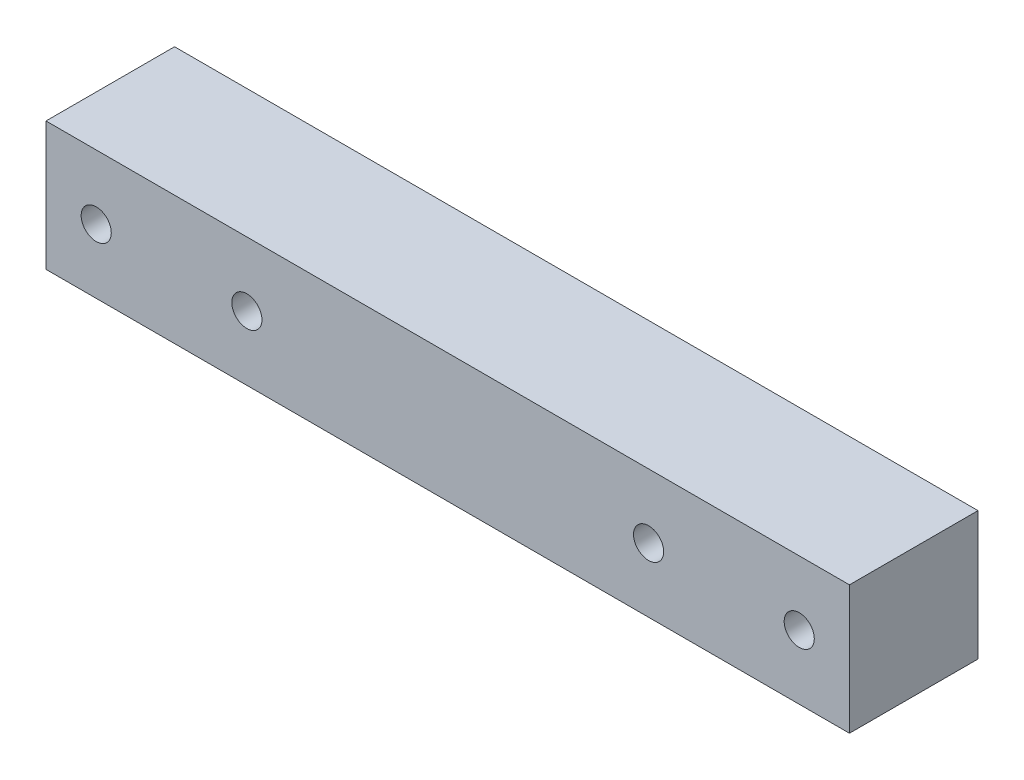
from build123d import *

# Parameters (mm, degrees)
ESBO_O1_W                = 80
ESBO_O1_H                = 12.8
RESSALTO_EXTRUS_O1_DEPTH = 12.8
ESBO_O2_R                = 1.5
CORTE_EXTRUS_O1_DEPTH    = 12.8


with BuildPart() as part:
    # Esboço1 → Ressalto-extrusão1 (new body)
    with BuildSketch(Plane.XY):
        with Locations((40, 6.4)):
            Rectangle(ESBO_O1_W, ESBO_O1_H)
    extrude(amount=RESSALTO_EXTRUS_O1_DEPTH)

    # Esboço2 → Corte-extrusão1 (cut)
    with BuildSketch(Plane.XY.offset(12.8)):
        with Locations((75, 6.4)):
            Circle(ESBO_O2_R)
        with Locations((60, 6.4)):
            Circle(ESBO_O2_R)
        with Locations((5, 6.4)):
            Circle(ESBO_O2_R)
        with Locations((20, 6.4)):
            Circle(ESBO_O2_R)
    extrude(amount=-CORTE_EXTRUS_O1_DEPTH, mode=Mode.SUBTRACT)


solid = part.part
